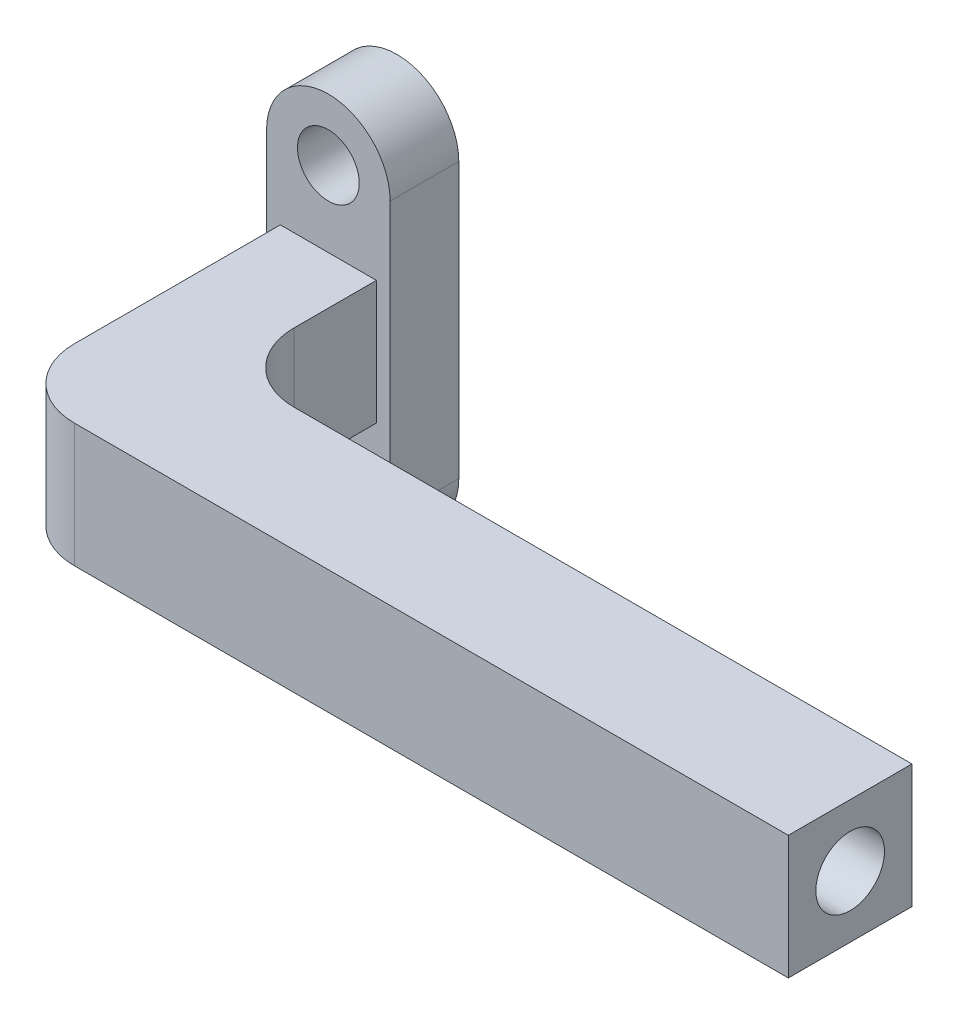
from build123d import *

# Parameters (mm, degrees)
SKETCH1_R           = 2.25
BOSS_EXTRUDE1_DEPTH = 5
SKETCH2_W           = 7
SKETCH2_H           = 9
BOSS_EXTRUDE2_DEPTH = 20
SKETCH4_W           = 9
SKETCH4_H           = 9
BOSS_EXTRUDE4_DEPTH = 50
SKETCH5_R           = 2.5
CUT_EXTRUDE1_DEPTH  = 25
FILLET1_R           = 5
FILLET2_R           = 5


with BuildPart() as part:
    # Sketch1 → Boss-Extrude1 (new body)
    with BuildSketch(Plane.XY):
        with BuildLine():
            ThreePointArc((4.5, 10), (0, 14.5), (-4.5, 10))
            Line((-4.5, 10), (-4.5, -10))
            ThreePointArc((-4.5, -10), (0, -14.5), (4.5, -10))
            Line((4.5, -10), (4.5, 10))
        make_face()
        with Locations((0, 10)):
            Circle(SKETCH1_R, mode=Mode.SUBTRACT)
        with Locations((0, -10)):
            Circle(SKETCH1_R, mode=Mode.SUBTRACT)
    extrude(amount=BOSS_EXTRUDE1_DEPTH)

    # Sketch2 → Boss-Extrude2 (add)
    with BuildSketch(Plane.XY.offset(5)):
        Rectangle(SKETCH2_W, SKETCH2_H)
    extrude(amount=BOSS_EXTRUDE2_DEPTH)

    # Sketch4 → Boss-Extrude4 (add)
    with BuildSketch(Plane(origin=(3.5, 0, 0), x_dir=(0, 0, -1), z_dir=(1, 0, 0))):
        with Locations((-20.5, 0)):
            Rectangle(SKETCH4_W, SKETCH4_H)
    extrude(amount=BOSS_EXTRUDE4_DEPTH)

    # Sketch5 → Cut-Extrude1 (cut)
    with BuildSketch(Plane(origin=(53.5, 0, 0), x_dir=(0, 0, -1), z_dir=(1, 0, 0))):
        with Locations((-20.5, 0)):
            Circle(SKETCH5_R)
    extrude(amount=-CUT_EXTRUDE1_DEPTH, mode=Mode.SUBTRACT)

    # Fillet1
    fillet1_edges = [part.edges().sort_by_distance(p)[0] for p in [
        (3.5, 0, 16),
    ]]
    fillet(fillet1_edges, radius=FILLET1_R)

    # Fillet2
    fillet2_edges = [part.edges().sort_by_distance(p)[0] for p in [
        (-3.5, 0, 25),
    ]]
    fillet(fillet2_edges, radius=FILLET2_R)


solid = part.part
